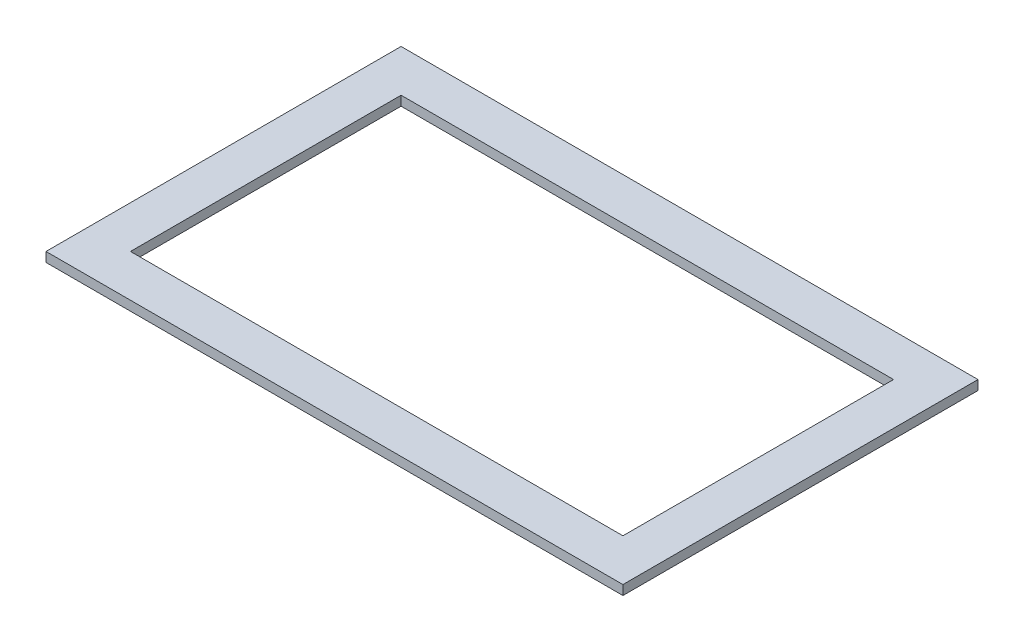
from build123d import *

# Parameters (mm, degrees)
SKETCH1_W           = 121.019327052
SKETCH1_H           = 74.483029124
SKETCH1_W_2         = 103.30309567
SKETCH1_H_2         = 56.76679774
BOSS_EXTRUDE1_DEPTH = 2


with BuildPart() as part:
    # Sketch1 → Boss-Extrude1 (new body)
    with BuildSketch(Plane(origin=(0, 0, 0), x_dir=(1, 0, 0), z_dir=(0, 1, 0))):
        Rectangle(SKETCH1_W, SKETCH1_H)
        Rectangle(SKETCH1_W_2, SKETCH1_H_2, mode=Mode.SUBTRACT)
    extrude(amount=BOSS_EXTRUDE1_DEPTH)


solid = part.part
